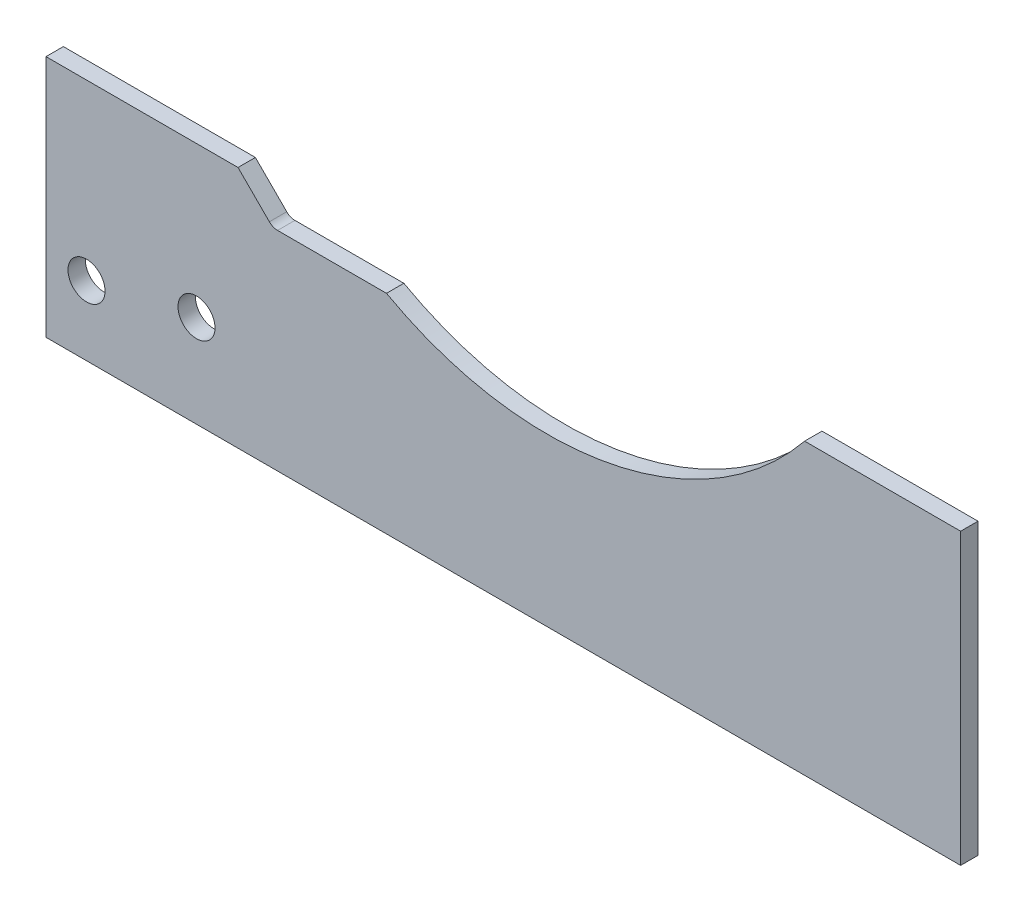
from build123d import *

# Parameters (mm, degrees)
SKETCH_1_R      = 1.6
EXTRUDE_1_DEPTH = 1.5


with BuildPart() as part:
    # Эскиз1 → Бобышка-Вытянуть1 (new body)
    with BuildSketch(Plane.XY):
        with BuildLine():
            Line((0, 20.99999864), (0, 0))
            Line((0, 0), (79, 0))
            Line((79, 0), (79, 25.0000008))
            Line((79, 25.0000008), (65.525211558, 25.0000008))
            ThreePointArc((65.525211558, 25.0000008), (48.741944539, 14.922513652), (29.408996509, 17.99999956))
            Line((29.408996509, 17.99999956), (20.000212839, 17.99999956))
            ThreePointArc((20.000212839, 17.99999956), (19.617529225, 18.076120064), (19.293105722, 18.292892918))
            Line((19.293105722, 18.292892918), (16.586, 20.99999864))
            Line((16.586, 20.99999864), (0, 20.99999864))
        make_face()
        with Locations((3.5, 6)):
            Circle(SKETCH_1_R, mode=Mode.SUBTRACT)
        with Locations((13, 8)):
            Circle(SKETCH_1_R, mode=Mode.SUBTRACT)
    extrude(amount=EXTRUDE_1_DEPTH)


solid = part.part
